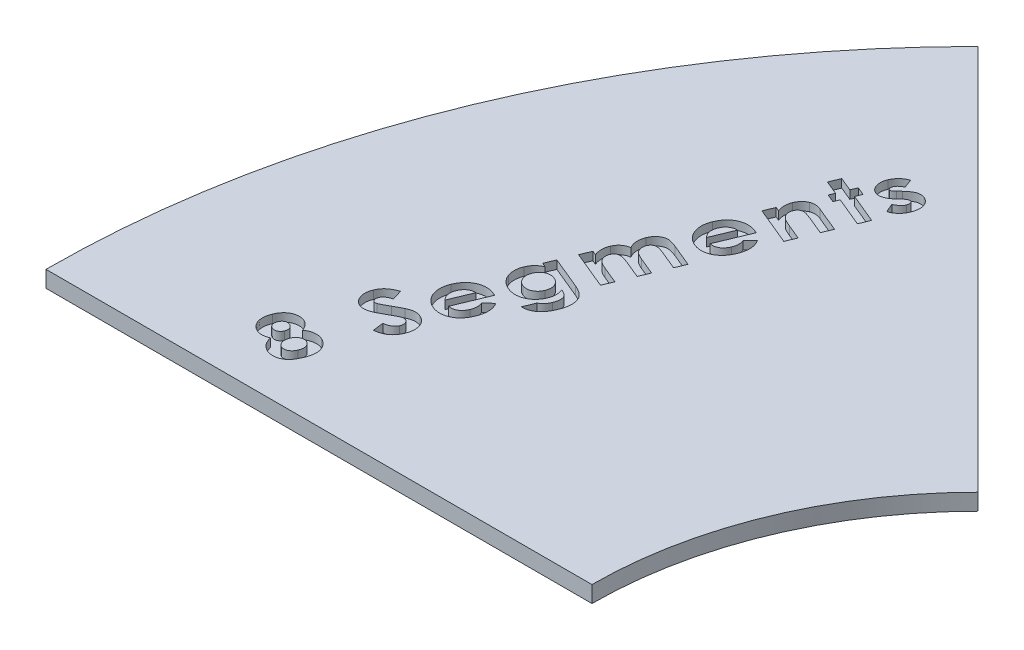
from build123d import *

# Parameters (mm, degrees)
BOSS_EXTRUDE1_DEPTH = 3.175
CUT_EXTRUDE1_DEPTH  = 1.5875


with BuildPart() as part:
    # Sketch1 → Boss-Extrude1 (new body)
    with BuildSketch(Plane(origin=(0, 0, 0), x_dir=(1, 0, 0), z_dir=(0, 1, 0))):
        with BuildLine():
            Line((0, 0), (105.210244843, 0))
            ThreePointArc((105.210244843, 0), (110.873217703, 28.469687102), (127, 52.605122421))
            Line((127, 52.605122421), (52.605122421, 127))
            ThreePointArc((52.605122421, 127), (13.671625882, 68.731904719), (0, 0))
        make_face()
    extrude(amount=BOSS_EXTRUDE1_DEPTH)

    # Sketch2 → Cut-Extrude1 (cut)
    with BuildSketch(Plane(origin=(0, 3.175, 0), x_dir=(1, 0, 0), z_dir=(0, 1, 0))):
        with BuildLine():
            add(Edge.make_bspline(
                [(34.894986461, 14.559342156), (35.015244675, 14.643832063), (35.252004447, 14.810172561), (35.636450357, 15.000750297), (36.033442296, 15.138098122), (36.440193733, 15.223660089), (36.850920666, 15.252640028), (37.258829751, 15.230213215), (37.660350133, 15.150178263), (37.916452634, 15.05473023), (38.04539378, 15.006674554)],
                knots=[0, 0, 0, 0, 1.057196094, 2.081367231, 3.077605999, 4.075701836, 5.06556388, 6.034121002, 7.010229537, 8, 8, 8, 8], degree=3))
            add(Edge.make_bspline(
                [(38.04539378, 15.006674554), (38.114450168, 14.976636756), (38.25139348, 14.917069849), (38.447013485, 14.809469601), (38.633808625, 14.691279857), (38.81046128, 14.559590718), (38.975418947, 14.414146489), (39.134236027, 14.259818954), (39.279788652, 14.088816469), (39.416877323, 13.9079265), (39.54185663, 13.718629218), (39.649321776, 13.521901832), (39.746644523, 13.322884194), (39.824526673, 13.115971452), (39.888127864, 12.904133149), (39.9370112, 12.687343799), (39.970887481, 12.465637209), (39.990662115, 12.238273523), (39.991397687, 12.003820147), (39.980077576, 11.761401268), (39.946237507, 11.511837077), (39.900280263, 11.252401236), (39.833291884, 10.985516856), (39.753496565, 10.708228606), (39.652658128, 10.424667221), (39.57670248, 10.234175591), (39.537915147, 10.136899581)],
                knots=[0, 0, 0, 0, 0.945079064, 1.874153276, 2.799661624, 3.718896423, 4.637060028, 5.559372917, 6.496756723, 7.453262601, 8.408120892, 9.341464594, 10.26616447, 11.187324281, 12.113682889, 13.041442723, 13.975081607, 14.927835092, 15.903895109, 16.916806437, 17.972234812, 19.063457995, 20.22340173, 21.425148361, 22.68513229, 24, 24, 24, 24], degree=3))
            add(Edge.make_bspline(
                [(39.537915147, 10.136899581), (39.494252939, 10.034044784), (39.409210207, 9.833710138), (39.270447786, 9.546949781), (39.129305191, 9.279744341), (38.983089664, 9.033333967), (38.832677483, 8.808026402), (38.678067017, 8.603713616), (38.51831843, 8.420613594), (38.355155034, 8.256421034), (38.184993864, 8.110732368), (38.009388956, 7.978507945), (37.825032054, 7.862872274), (37.634197459, 7.759328609), (37.43626357, 7.671228285), (37.2307295, 7.596544531), (37.018482456, 7.534496283), (36.726700487, 7.47355268), (36.354509755, 7.432201078), (35.905528852, 7.456202082), (35.455490199, 7.539344886), (35.16717524, 7.646353609), (35.020069928, 7.700952065)],
                knots=[0, 0, 0, 0, 1.153938997, 2.247575859, 3.289190737, 4.274343085, 5.205562773, 6.085844791, 6.918733811, 7.713557295, 8.474373638, 9.23055424, 9.981822346, 10.71989077, 11.471371589, 12.217195007, 12.977170591, 13.753067799, 15.294251767, 16.828784307, 18.381968536, 20, 20, 20, 20], degree=3))
            add(Edge.make_bspline(
                [(35.020069928, 7.700952065), (34.89598745, 7.75691979), (34.652186862, 7.86688668), (34.320880074, 8.089003514), (34.02111523, 8.342574627), (33.761212656, 8.639983628), (33.533228131, 8.972446173), (33.350360815, 9.347282833), (33.190312805, 9.754319825), (33.121837813, 10.044639747), (33.086576338, 10.194141168)],
                knots=[0, 0, 0, 0, 0.990997465, 1.947138454, 2.897303808, 3.846462571, 4.818345321, 5.827714344, 6.881372701, 8, 8, 8, 8], degree=3))
            add(Edge.make_bspline(
                [(33.086576338, 10.194141168), (32.982018661, 10.149745312), (32.777390437, 10.062858866), (32.463754098, 9.968720811), (32.155748833, 9.900366576), (31.851408462, 9.869332156), (31.552730989, 9.867706568), (31.260078291, 9.903385299), (30.971689888, 9.966904356), (30.787683151, 10.037697463), (30.695150056, 10.073297818)],
                knots=[0, 0, 0, 0, 1.104929131, 2.162439829, 3.182414216, 4.171487361, 5.134527059, 6.083335384, 7.036149921, 8, 8, 8, 8], degree=3))
            add(Edge.make_bspline(
                [(30.695150056, 10.073297818), (30.572486902, 10.129994294), (30.330989453, 10.241617499), (30.002396806, 10.466557425), (29.712755533, 10.733525045), (29.460742914, 11.039109688), (29.258409236, 11.381910636), (29.101158144, 11.750694676), (29.000408078, 12.146801232), (28.946583584, 12.56407002), (28.950854483, 13.000001062), (29.00588371, 13.447747831), (29.119878444, 13.904746651), (29.233403493, 14.204226222), (29.291671157, 14.357936573)],
                knots=[0, 0, 0, 0, 0.962683188, 1.895316776, 2.826532283, 3.765074047, 4.710051971, 5.65665559, 6.61529115, 7.616384876, 8.649856013, 9.71660434, 10.828028409, 12, 12, 12, 12], degree=3))
            add(Edge.make_bspline(
                [(29.291671157, 14.357936573), (29.35745835, 14.506016706), (29.485665547, 14.794597775), (29.731562937, 15.187686738), (30.001455547, 15.54024706), (30.309886438, 15.83997656), (30.641845092, 16.093011291), (30.997718087, 16.296146666), (31.376167552, 16.442021169), (31.77023225, 16.538404654), (32.171237488, 16.57717776), (32.568853779, 16.566995937), (32.957775898, 16.494244209), (33.204233579, 16.404457214), (33.328263037, 16.359272044)],
                knots=[0, 0, 0, 0, 1.158258468, 2.257233707, 3.309350479, 4.328585269, 5.324889877, 6.289658742, 7.250416187, 8.218215741, 9.183898784, 10.125049342, 11.0564339, 12, 12, 12, 12], degree=3))
            add(Edge.make_bspline(
                [(33.328263037, 16.359272044), (33.413353168, 16.321650946), (33.581221909, 16.24743075), (33.813381767, 16.10327124), (34.025073948, 15.937344084), (34.218056168, 15.743268931), (34.399939361, 15.514908461), (34.573528731, 15.24123664), (34.739118342, 14.917504671), (34.841208602, 14.682915939), (34.894986461, 14.559342156)],
                knots=[0, 0, 0, 0, 0.90715432, 1.789665305, 2.659004758, 3.527166782, 4.454652015, 5.503172596, 6.684751796, 8, 8, 8, 8], degree=3))
        make_face()
        with BuildLine():
            add(Edge.make_bspline(
                [(31.055560046, 13.552314244), (31.026568356, 13.471856019), (30.970425321, 13.316046924), (30.935009289, 13.074113914), (30.950308706, 12.838171831), (31.012119872, 12.613384214), (31.115645532, 12.406252929), (31.260566029, 12.227569058), (31.442583154, 12.078345462), (31.585906455, 12.011541863), (31.659776792, 11.977110585)],
                knots=[0, 0, 0, 0, 1.084156143, 2.099491825, 3.079714819, 4.065958418, 5.04123908, 5.998516089, 6.968414138, 8, 8, 8, 8], degree=3))
            add(Edge.make_bspline(
                [(31.659776792, 11.977110585), (31.737379209, 11.94980408), (31.888214393, 11.896728649), (32.126576488, 11.873078822), (32.361932824, 11.902030753), (32.590595355, 11.979381438), (32.803509969, 12.098062438), (32.987116004, 12.259627139), (33.14177674, 12.455079341), (33.213180267, 12.607166797), (33.249820863, 12.685210211)],
                knots=[0, 0, 0, 0, 1.014990233, 1.972828228, 2.932579668, 3.92791117, 4.941884171, 5.927219846, 6.93635646, 8, 8, 8, 8], degree=3))
            add(Edge.make_bspline(
                [(33.249820863, 12.685210211), (33.279653476, 12.767745356), (33.337427199, 12.9275826), (33.37303614, 13.176276882), (33.354794684, 13.418477953), (33.291553992, 13.650084372), (33.183162911, 13.863452395), (33.03240297, 14.049549734), (32.838114367, 14.201736444), (32.687547163, 14.272516002), (32.609563117, 14.309175222)],
                knots=[0, 0, 0, 0, 1.07396406, 2.079834688, 3.052591258, 4.031998903, 5.004485396, 5.965130557, 6.946069604, 8, 8, 8, 8], degree=3))
            add(Edge.make_bspline(
                [(32.609563117, 14.309175222), (32.532682574, 14.336387459), (32.383976827, 14.389022573), (32.150377259, 14.413943628), (31.92258137, 14.381884461), (31.70335383, 14.303327533), (31.50098752, 14.176755877), (31.322692758, 14.007620144), (31.16891758, 13.798139139), (31.094415997, 13.636576487), (31.055560046, 13.552314244)],
                knots=[0, 0, 0, 0, 1.006594127, 1.946998898, 2.873111781, 3.829953932, 4.807657852, 5.803449211, 6.854399243, 8, 8, 8, 8], degree=3))
        make_face(mode=Mode.SUBTRACT)
        with BuildLine():
            add(Edge.make_bspline(
                [(34.996749282, 12.011031525), (34.952922841, 11.892800801), (34.867977924, 11.663644638), (34.813568255, 11.30702709), (34.818057477, 10.958786678), (34.877383076, 10.678183104), (34.952672786, 10.467395422), (35.021986639, 10.321886211), (35.097944669, 10.187237276), (35.19243766, 10.071053266), (35.290694987, 9.961676331), (35.406907995, 9.872653973), (35.530578398, 9.791371736), (35.620820138, 9.750581167), (35.66668785, 9.729848299)],
                knots=[0, 0, 0, 0, 1.717655024, 3.329178916, 4.892385349, 6.449626005, 7.218668733, 7.943729169, 8.648610728, 9.322160396, 9.984211036, 10.650186634, 11.313922241, 12, 12, 12, 12], degree=3))
            add(Edge.make_bspline(
                [(35.66668785, 9.729848299), (35.763795078, 9.695105946), (35.954720773, 9.626797869), (36.26049234, 9.612390345), (36.566095605, 9.655514044), (36.811995768, 9.754748379), (37.004446062, 9.857935268), (37.139647981, 9.957475182), (37.268339722, 10.067758598), (37.386458677, 10.193737628), (37.498374455, 10.332494571), (37.598950395, 10.487040845), (37.691131156, 10.655781305), (37.743146008, 10.775303839), (37.769786141, 10.836518972)],
                knots=[0, 0, 0, 0, 1.391368532, 2.735615157, 4.101577094, 5.548329535, 6.30311976, 7.058335613, 7.819123302, 8.598569138, 9.396179257, 10.233328724, 11.095174654, 12, 12, 12, 12], degree=3))
            add(Edge.make_bspline(
                [(37.769786141, 10.836518972), (37.794860907, 10.899043064), (37.843833645, 11.021156906), (37.898132701, 11.206661963), (37.939370648, 11.386305616), (37.963298865, 11.561571376), (37.969385502, 11.731956201), (37.960923994, 11.897939184), (37.938560717, 12.059505358), (37.897331226, 12.214762669), (37.843466248, 12.362195507), (37.774249697, 12.498370201), (37.696864495, 12.625497032), (37.601777075, 12.738045142), (37.495358177, 12.840640809), (37.375596051, 12.931801416), (37.244179271, 13.013669732), (37.148483313, 13.055938662), (37.099847572, 13.077421082)],
                knots=[0, 0, 0, 0, 1.230493708, 2.403238625, 3.528140521, 4.596690784, 5.630649897, 6.639375739, 7.63117503, 8.605411454, 9.569839013, 10.493990592, 11.393444885, 12.283109541, 13.178288218, 14.09017477, 15.029365836, 16, 16, 16, 16], degree=3))
            add(Edge.make_bspline(
                [(37.099847572, 13.077421082), (37.04996952, 13.095947768), (36.951556352, 13.13250232), (36.799904893, 13.171973006), (36.647436699, 13.18998884), (36.495121625, 13.193468597), (36.34399195, 13.174608253), (36.191467869, 13.14363987), (36.039633118, 13.092076622), (35.88937236, 13.024138677), (35.744973163, 12.942046835), (35.607176587, 12.848928273), (35.482023041, 12.739339518), (35.365842237, 12.618110114), (35.255827314, 12.486414578), (35.159732119, 12.339692739), (35.07107185, 12.181267553), (35.021943273, 12.068738426), (34.996749282, 12.011031525)],
                knots=[0, 0, 0, 0, 0.970593606, 1.915054551, 2.850672034, 3.766261023, 4.687552417, 5.623258748, 6.6018704, 7.606057281, 8.628050718, 9.629501955, 10.635095203, 11.656437688, 12.691605124, 13.760902874, 14.851751903, 16, 16, 16, 16], degree=3))
        make_face(mode=Mode.SUBTRACT)
        with BuildLine():
            Line((37.82377329, 30.509227798), (38.421629861, 28.526972857))
            add(Edge.make_bspline(
                [(38.421629861, 28.526972857), (38.315779379, 28.496135542), (38.111482739, 28.436618007), (37.825363384, 28.323698511), (37.568333869, 28.19920292), (37.342928027, 28.059438331), (37.147100309, 27.906650133), (36.984096023, 27.737817705), (36.851939662, 27.554206932), (36.788687547, 27.420669003), (36.757383734, 27.354580362)],
                knots=[0, 0, 0, 0, 1.255085698, 2.422377185, 3.498629962, 4.503637447, 5.437583008, 6.319883282, 7.168501178, 8, 8, 8, 8], degree=3))
            add(Edge.make_bspline(
                [(36.757383734, 27.354580362), (36.733463573, 27.290875941), (36.687533248, 27.168553822), (36.653097371, 26.980843259), (36.649729543, 26.800644305), (36.680077496, 26.63152309), (36.733404095, 26.480577195), (36.807596005, 26.353066363), (36.905401513, 26.255680549), (36.98371708, 26.214998123), (37.022391079, 26.19490822)],
                knots=[0, 0, 0, 0, 1.243573393, 2.387848927, 3.47452098, 4.525100094, 5.515332756, 6.391621974, 7.205746542, 8, 8, 8, 8], degree=3))
            add(Edge.make_bspline(
                [(37.022391079, 26.19490822), (37.063685249, 26.180503164), (37.147413656, 26.151295352), (37.281538553, 26.138544217), (37.421596578, 26.145992639), (37.51315055, 26.171177011), (37.560886004, 26.184307926)],
                knots=[0, 0, 0, 0, 0.95245967, 1.931215204, 2.921353408, 4, 4, 4, 4], degree=3))
            add(Edge.make_bspline(
                [(37.560886004, 26.184307926), (37.599199766, 26.198054028), (37.688184769, 26.229979813), (37.836052385, 26.295267844), (38.018846877, 26.379881817), (38.233929046, 26.488404889), (38.482717167, 26.619023401), (38.766565482, 26.768106505), (39.082072744, 26.943286407), (39.303600258, 27.066915343), (39.420177537, 27.131974192)],
                knots=[0, 0, 0, 0, 0.467592245, 1.08599873, 1.856165475, 2.782174495, 3.853593694, 5.08498372, 6.465993399, 8, 8, 8, 8], degree=3))
            add(Edge.make_bspline(
                [(39.420177537, 27.131974192), (39.528117194, 27.1937816), (39.732971562, 27.311083414), (40.026595124, 27.472608842), (40.284699551, 27.62097328), (40.512738269, 27.745239742), (40.709370297, 27.848888352), (40.871371631, 27.936773891), (41.003072849, 28.002838084), (41.08081923, 28.038802463), (41.114104487, 28.054199753)],
                knots=[0, 0, 0, 0, 1.547400198, 2.936749091, 4.169008029, 5.25096652, 6.167378643, 6.934330828, 7.543759182, 8, 8, 8, 8], degree=3))
            add(Edge.make_bspline(
                [(41.114104487, 28.054199753), (41.246196869, 28.111211198), (41.499372148, 28.220482362), (41.874516302, 28.347311925), (42.226146744, 28.42865683), (42.556595124, 28.47256976), (42.874651776, 28.470396218), (43.188125851, 28.438431354), (43.499392547, 28.362740742), (43.700568742, 28.287372275), (43.802338995, 28.249245159)],
                knots=[0, 0, 0, 0, 1.240787128, 2.378158539, 3.410341221, 4.350204943, 5.246327956, 6.147743487, 7.062987476, 8, 8, 8, 8], degree=3))
            add(Edge.make_bspline(
                [(43.802338995, 28.249245159), (43.899410203, 28.205947867), (44.089739593, 28.121054031), (44.354486877, 27.962768747), (44.593754467, 27.781151328), (44.809524353, 27.577192325), (44.998340286, 27.348192906), (45.165510844, 27.099013619), (45.305121085, 26.826106386), (45.418815167, 26.534038736), (45.506243412, 26.227597535), (45.560500017, 25.910541691), (45.586487599, 25.58696123), (45.580366312, 25.25662815), (45.538359865, 24.920549065), (45.467141252, 24.577824671), (45.369199285, 24.226459642), (45.277920254, 23.995665491), (45.2312586, 23.877683995)],
                knots=[0, 0, 0, 0, 0.989442286, 1.940018594, 2.865580513, 3.782865304, 4.699039251, 5.624694804, 6.572714812, 7.548219353, 8.540154878, 9.535818554, 10.53952318, 11.560054073, 12.607635655, 13.689506505, 14.818880466, 16, 16, 16, 16], degree=3))
            add(Edge.make_bspline(
                [(45.2312586, 23.877683995), (45.191302287, 23.786048105), (45.112807963, 23.606029058), (44.978829992, 23.347458048), (44.829510294, 23.106543633), (44.671617798, 22.878318549), (44.498322106, 22.668742724), (44.316655716, 22.471409333), (44.118179463, 22.294344519), (43.909800907, 22.130092258), (43.688576665, 21.979644785), (43.449779605, 21.850163234), (43.198740732, 21.729726213), (42.931646737, 21.625930201), (42.648235412, 21.540436513), (42.350927691, 21.46462351), (42.037443264, 21.408922627), (41.823032738, 21.381479505), (41.714081116, 21.367534422)],
                knots=[0, 0, 0, 0, 1.050302474, 2.063323122, 3.056720699, 4.027035708, 4.976903813, 5.912087026, 6.842689239, 7.76818148, 8.69910954, 9.649732038, 10.619649156, 11.623565597, 12.657064265, 13.728676382, 14.845838428, 16, 16, 16, 16], degree=3))
            Line((41.714081116, 21.367534422), (41.470274359, 23.44095189))
            add(Edge.make_bspline(
                [(41.470274359, 23.44095189), (41.597874584, 23.461481197), (41.843132139, 23.500940121), (42.190290651, 23.591114307), (42.499433058, 23.70856202), (42.774083375, 23.844807856), (43.011070436, 24.008821264), (43.206991253, 24.200169963), (43.372356565, 24.41142543), (43.446947887, 24.571354939), (43.484330181, 24.651505442)],
                knots=[0, 0, 0, 0, 1.259437608, 2.420737008, 3.489065932, 4.47801951, 5.403001476, 6.284802643, 7.140409212, 8, 8, 8, 8], degree=3))
            add(Edge.make_bspline(
                [(43.484330181, 24.651505442), (43.515307793, 24.73550656), (43.575354266, 24.898332892), (43.618567232, 25.150098893), (43.616773819, 25.395648414), (43.572023442, 25.629221663), (43.49413629, 25.84087318), (43.3848602, 26.021119868), (43.242618126, 26.162831541), (43.126523205, 26.221071676), (43.068798664, 26.250029748)],
                knots=[0, 0, 0, 0, 1.177356981, 2.282168659, 3.343301441, 4.39479724, 5.399223176, 6.298042895, 7.153755474, 8, 8, 8, 8], degree=3))
            add(Edge.make_bspline(
                [(43.068798664, 26.250029748), (43.012097023, 26.269244416), (42.896023617, 26.308578585), (42.705488431, 26.325629741), (42.502818617, 26.30879328), (42.323344834, 26.270302486), (42.167561818, 26.2165372), (42.027228129, 26.163710231), (41.870999603, 26.09029422), (41.692805491, 26.005682612), (41.497573473, 25.902834987), (41.279417133, 25.789705504), (41.046095933, 25.654561416), (40.883046842, 25.56095224), (40.798215732, 25.512249299)],
                knots=[0, 0, 0, 0, 0.872511462, 1.786110147, 2.769923426, 3.837503738, 4.458039612, 5.177296719, 6.027769003, 6.979340795, 8.060226658, 9.252196877, 10.570374197, 12, 12, 12, 12], degree=3))
            add(Edge.make_bspline(
                [(40.798215732, 25.512249299), (40.636768492, 25.418291978), (40.327420001, 25.238260684), (39.875916633, 24.989743463), (39.460308845, 24.769283267), (39.078512145, 24.579007119), (38.729759327, 24.422585413), (38.417107964, 24.291135152), (38.136723306, 24.192728941), (37.885943863, 24.122577908), (37.655420813, 24.076945504), (37.436458559, 24.049521617), (37.223977862, 24.03632557), (37.017842415, 24.038563734), (36.818327752, 24.054213549), (36.625877152, 24.089818573), (36.43901836, 24.136275357), (36.320221605, 24.183076443), (36.261289984, 24.206293103)],
                knots=[0, 0, 0, 0, 1.834395707, 3.514879204, 5.060893315, 6.454463483, 7.703134294, 8.814085874, 9.784205908, 10.619323197, 11.369267195, 12.089764372, 12.78501841, 13.458239954, 14.112963858, 14.747362741, 15.378603024, 16, 16, 16, 16], degree=3))
            add(Edge.make_bspline(
                [(36.261289984, 24.206293103), (36.179051838, 24.243297202), (36.017146128, 24.316148736), (35.792546523, 24.457081682), (35.586290328, 24.616781724), (35.402351754, 24.802793411), (35.235720499, 25.008372403), (35.092082829, 25.239351975), (34.966914122, 25.4907599), (34.860893541, 25.76059668), (34.781765989, 26.044170292), (34.728172147, 26.333662834), (34.7026377, 26.625441898), (34.704965961, 26.919994547), (34.734863681, 27.217340507), (34.79288318, 27.51725292), (34.877596486, 27.820276519), (34.954358969, 28.018739196), (34.993494845, 28.119921575)],
                knots=[0, 0, 0, 0, 0.945777067, 1.861991267, 2.776250795, 3.678601881, 4.602086906, 5.548969159, 6.527780765, 7.547332088, 8.587858808, 9.613788023, 10.634121904, 11.658010215, 12.701890797, 13.767017058, 14.861556599, 16, 16, 16, 16], degree=3))
            add(Edge.make_bspline(
                [(34.993494845, 28.119921575), (35.051412187, 28.247898206), (35.166706845, 28.502658203), (35.390158087, 28.857694086), (35.650013234, 29.186384344), (35.899194692, 29.436819916), (36.120787594, 29.625574272), (36.308056497, 29.763315189), (36.514921501, 29.8962594), (36.738700914, 30.028654847), (36.984824552, 30.151941134), (37.245700311, 30.278027397), (37.527916493, 30.396627592), (37.723196766, 30.470949356), (37.82377329, 30.509227798)],
                knots=[0, 0, 0, 0, 1.320847626, 2.629379544, 3.936135346, 5.257719604, 5.946690134, 6.674352171, 7.443653319, 8.260426475, 9.120106871, 10.03345656, 10.987157783, 12, 12, 12, 12], degree=3))
        make_face()
        with BuildLine():
            Line((47.556724494, 38.901769906), (44.957532453, 32.626395974))
            add(Edge.make_bspline(
                [(44.957532453, 32.626395974), (45.025199345, 32.613270861), (45.158406707, 32.58743309), (45.359182313, 32.568258044), (45.555891653, 32.567737479), (45.748800531, 32.587811827), (45.937915502, 32.623097051), (46.12333535, 32.678649479), (46.303786456, 32.753736366), (46.479998682, 32.844722676), (46.649668816, 32.953127501), (46.811285652, 33.077434314), (46.959708189, 33.221571499), (47.099789183, 33.378991973), (47.232602539, 33.550356808), (47.350422738, 33.741371479), (47.461453313, 33.946160077), (47.524585571, 34.091546396), (47.556724494, 34.165558634)],
                knots=[0, 0, 0, 0, 0.999506199, 1.967603067, 2.921040898, 3.848324603, 4.777250371, 5.708154082, 6.650559525, 7.608890338, 8.581536354, 9.567917048, 10.561305486, 11.577859283, 12.623615545, 13.701638693, 14.829966497, 16, 16, 16, 16], degree=3))
            add(Edge.make_bspline(
                [(47.556724494, 34.165558634), (47.591603563, 34.256162844), (47.660439128, 34.434974725), (47.733523657, 34.709264402), (47.78407444, 34.982079049), (47.804620084, 35.254904549), (47.800480911, 35.52742066), (47.770821809, 35.800103394), (47.713951642, 36.072165481), (47.655924241, 36.249344881), (47.626686433, 36.338618864)],
                knots=[0, 0, 0, 0, 1.046210875, 2.064748831, 3.055749339, 4.034100705, 5.009599036, 5.990795142, 6.987637831, 8, 8, 8, 8], degree=3))
            Line((47.626686433, 36.338618864), (49.025925215, 37.689096295))
            add(Edge.make_bspline(
                [(49.025925215, 37.689096295), (49.069803153, 37.609648459), (49.156474624, 37.452716271), (49.2720523, 37.212051422), (49.369516993, 36.968312516), (49.449799795, 36.72157632), (49.516019381, 36.474071418), (49.565253936, 36.224113648), (49.597096853, 35.971920628), (49.611174861, 35.716948566), (49.611984306, 35.458508878), (49.593883884, 35.195976429), (49.562749991, 34.928263342), (49.51309875, 34.655880341), (49.447704782, 34.378344323), (49.363443595, 34.096026894), (49.267376799, 33.807325578), (49.190205416, 33.616078529), (49.151008682, 33.518940712)],
                knots=[0, 0, 0, 0, 1.003634881, 1.982465802, 2.950503462, 3.904525821, 4.850510779, 5.782443743, 6.719866401, 7.659339425, 8.605033763, 9.576189917, 10.567916247, 11.584342194, 12.636469959, 13.719720965, 14.841805265, 16, 16, 16, 16], degree=3))
            add(Edge.make_bspline(
                [(49.151008682, 33.518940712), (49.086431255, 33.370708787), (48.960026669, 33.080557943), (48.731040205, 32.67508994), (48.480590572, 32.303203855), (48.203924924, 31.966487764), (47.90235134, 31.664508377), (47.576280271, 31.397112514), (47.223809898, 31.167425425), (46.851035, 30.973374808), (46.464988697, 30.819757717), (46.074030421, 30.705303046), (45.680932018, 30.635461203), (45.285060203, 30.606720642), (44.887576667, 30.62448545), (44.48800122, 30.685473165), (44.085533046, 30.785311254), (43.824444792, 30.887125349), (43.691857373, 30.938829201)],
                knots=[0, 0, 0, 0, 1.146602934, 2.244373534, 3.298563833, 4.324518666, 5.331476356, 6.322147264, 7.310976432, 8.311232562, 9.299158661, 10.254479451, 11.19676241, 12.126690195, 13.065216707, 14.013338492, 14.991121514, 16, 16, 16, 16], degree=3))
            add(Edge.make_bspline(
                [(43.691857373, 30.938829201), (43.558388156, 30.997664621), (43.295840929, 31.113399745), (42.93085981, 31.329601505), (42.596828876, 31.572000473), (42.296938185, 31.844995401), (42.027401555, 32.145534007), (41.791950458, 32.476093305), (41.586549042, 32.834068198), (41.419375026, 33.218724911), (41.286102691, 33.617920578), (41.193525487, 34.026226745), (41.145509009, 34.439090652), (41.136377539, 34.855897253), (41.170751633, 35.276456198), (41.24942465, 35.700213783), (41.363922709, 36.129830986), (41.473632975, 36.410224177), (41.529397437, 36.552744799)],
                knots=[0, 0, 0, 0, 1.039554709, 2.044907523, 3.018774064, 3.978622492, 4.931724432, 5.8926442, 6.867918403, 7.869968102, 8.878902825, 9.865700747, 10.850372433, 11.838482467, 12.834696674, 13.854002584, 14.909214283, 16, 16, 16, 16], degree=3))
            add(Edge.make_bspline(
                [(41.529397437, 36.552744799), (41.595003999, 36.700806294), (41.723558624, 36.990929559), (41.950800581, 37.400031494), (42.206042824, 37.771739849), (42.484354568, 38.109371433), (42.788902092, 38.410166962), (43.119849384, 38.674341185), (43.475181863, 38.904669147), (43.854024219, 39.096924665), (44.248310114, 39.248954468), (44.652451619, 39.358552339), (45.064058918, 39.423059541), (45.482902277, 39.439050361), (45.908477025, 39.411046037), (46.339880456, 39.337425137), (46.779440766, 39.221908376), (47.066574109, 39.109649086), (47.213274975, 39.052294078)],
                knots=[0, 0, 0, 0, 1.112351366, 2.179628199, 3.209947748, 4.206534332, 5.181656861, 6.145483003, 7.111166465, 8.086192275, 9.059172646, 10.009709944, 10.958099272, 11.915445672, 12.88377453, 13.883196023, 14.918492108, 16, 16, 16, 16], degree=3))
            Line((47.213274975, 39.052294078), (47.556724494, 38.901769906))
        make_face()
        with BuildLine():
            add(Edge.make_bspline(
                [(45.320062501, 37.530091888), (45.207477503, 37.534360857), (44.983363448, 37.542858758), (44.649192885, 37.479110021), (44.324682239, 37.358529938), (44.015869771, 37.179199278), (43.727131161, 36.955071759), (43.477692589, 36.679593542), (43.258853768, 36.367260962), (43.15252669, 36.132161107), (43.09824092, 36.012129815)],
                knots=[0, 0, 0, 0, 0.937368577, 1.865945521, 2.815397792, 3.813532689, 4.833709448, 5.851720568, 6.903186246, 8, 8, 8, 8], degree=3))
            add(Edge.make_bspline(
                [(43.09824092, 36.012129815), (43.048045851, 35.877675673), (42.950010009, 35.615073686), (42.877195738, 35.206272309), (42.861989564, 34.800744535), (42.906436451, 34.53690467), (42.928636219, 34.405125274)],
                knots=[0, 0, 0, 0, 1.048066872, 2.046976308, 3.024528454, 4, 4, 4, 4], degree=3))
            add(Edge.make_bspline(
                [(42.928636219, 34.405125274), (42.952875203, 34.318651467), (43.004124245, 34.135817901), (43.141781456, 33.864882025), (43.330581924, 33.581801988), (43.484944899, 33.398006219), (43.566773906, 33.30057466)],
                knots=[0, 0, 0, 0, 0.835012607, 1.765486412, 2.815467062, 4, 4, 4, 4], degree=3))
            Line((43.566773906, 33.30057466), (45.320062501, 37.530091888))
        make_face(mode=Mode.SUBTRACT)
        with BuildLine():
            Line((46.84390101, 48.856362958), (47.649523339, 50.8025769))
            Line((47.649523339, 50.8025769), (53.82313445, 48.243665976))
            add(Edge.make_bspline(
                [(53.82313445, 48.243665976), (53.969589142, 48.180542422), (54.25309424, 48.058348662), (54.650536967, 47.849987075), (55.007593733, 47.629601918), (55.326580231, 47.398871752), (55.603180779, 47.153203618), (55.838297398, 46.894111458), (56.038221431, 46.625762675), (56.136588021, 46.431153911), (56.18487991, 46.335613091)],
                knots=[0, 0, 0, 0, 1.232213278, 2.385302534, 3.464452739, 4.472752186, 5.424340862, 6.317473201, 7.173983813, 8, 8, 8, 8], degree=3))
            add(Edge.make_bspline(
                [(56.18487991, 46.335613091), (56.240996359, 46.204794717), (56.353486738, 45.942557733), (56.453951851, 45.521616078), (56.509413423, 45.085182154), (56.515749602, 44.629209154), (56.46721996, 44.15537471), (56.366964772, 43.663674689), (56.221363711, 43.15245758), (56.088182732, 42.813167023), (56.019515326, 42.638230613)],
                knots=[0, 0, 0, 0, 0.894840978, 1.793787764, 2.713246973, 3.661089344, 4.658149883, 5.706170744, 6.817313807, 8, 8, 8, 8], degree=3))
            add(Edge.make_bspline(
                [(56.019515326, 42.638230613), (55.94083962, 42.45610552), (55.789671226, 42.106168301), (55.530386424, 41.621154557), (55.257498393, 41.1951123), (54.970107071, 40.825051161), (54.66269993, 40.510765068), (54.341307378, 40.237688165), (53.998384968, 40.010566487), (53.638489571, 39.824404418), (53.262954043, 39.68333757), (52.871700192, 39.592661474), (52.468243787, 39.543449719), (52.195044443, 39.550158386), (52.057125503, 39.553545116)],
                knots=[0, 0, 0, 0, 1.323873625, 2.543705805, 3.666386811, 4.697831038, 5.665251407, 6.596001571, 7.507912599, 8.404566619, 9.295681651, 10.177861967, 11.080131959, 12, 12, 12, 12], degree=3))
            Line((52.057125503, 39.553545116), (52.949670241, 41.707524817))
            add(Edge.make_bspline(
                [(52.949670241, 41.707524817), (53.019922039, 41.737379978), (53.161024173, 41.797344665), (53.35743037, 41.924454222), (53.544779895, 42.075279045), (53.722098147, 42.255092044), (53.886371199, 42.465028969), (54.04488273, 42.699947002), (54.185536262, 42.967436413), (54.269482559, 43.157129674), (54.312868024, 43.255167712)],
                knots=[0, 0, 0, 0, 0.862758365, 1.732867346, 2.637491876, 3.582264396, 4.584342987, 5.651654991, 6.786318835, 8, 8, 8, 8], degree=3))
            add(Edge.make_bspline(
                [(54.312868024, 43.255167712), (54.361655804, 43.380906652), (54.454740662, 43.620810811), (54.554204208, 43.975259164), (54.606972143, 44.304117757), (54.616072036, 44.606283212), (54.589228041, 44.880638782), (54.531110532, 45.127709619), (54.439121272, 45.345971801), (54.334018374, 45.507029126), (54.228704055, 45.623978929), (54.130255228, 45.709958503), (54.014203396, 45.797972286), (53.879089003, 45.885581358), (53.725746832, 45.975060939), (53.553614172, 46.063786369), (53.362192538, 46.152514746), (53.227554248, 46.210179323), (53.157435999, 46.240210447)],
                knots=[0, 0, 0, 0, 1.727353437, 3.295711531, 4.706883854, 5.984034755, 7.157937912, 8.229585478, 9.223483754, 10.177742941, 10.677775558, 11.235691424, 11.849574508, 12.54267662, 13.297383517, 14.123498569, 15.022737179, 16, 16, 16, 16], degree=3))
            add(Edge.make_bspline(
                [(53.157435999, 46.240210447), (53.19814896, 46.123637887), (53.277794371, 45.895590867), (53.351768205, 45.54808884), (53.397413717, 45.209153046), (53.400313212, 44.874904297), (53.370287887, 44.541124555), (53.304504537, 44.203259309), (53.210647433, 43.855368077), (53.120831048, 43.626822533), (53.074753708, 43.509574763)],
                knots=[0, 0, 0, 0, 1.056011142, 2.065839458, 3.035286268, 3.979082649, 4.920569059, 5.899407769, 6.92236029, 8, 8, 8, 8], degree=3))
            add(Edge.make_bspline(
                [(53.074753708, 43.509574763), (53.018304322, 43.382702256), (52.907131732, 43.132836912), (52.704618866, 42.781683961), (52.474984483, 42.460263434), (52.218855433, 42.167414483), (51.936193608, 41.903798551), (51.626228736, 41.66913509), (51.290438501, 41.463050245), (50.931501441, 41.288861998), (50.559095032, 41.14592571), (50.177815649, 41.046678283), (49.793650211, 40.985605973), (49.40615878, 40.969571389), (49.015416658, 40.992960508), (48.621637657, 41.058119947), (48.223068005, 41.160427073), (47.963780952, 41.261675722), (47.831848393, 41.313193887)],
                knots=[0, 0, 0, 0, 1.04887533, 2.065676805, 3.057127916, 4.029759462, 5.000864989, 5.972851204, 6.962978153, 7.973293486, 8.984018067, 9.972371898, 10.945223346, 11.918133426, 12.897209456, 13.898108625, 14.93049844, 16, 16, 16, 16], degree=3))
            add(Edge.make_bspline(
                [(47.831848393, 41.313193887), (47.693436285, 41.374140266), (47.422483602, 41.493447637), (47.045879226, 41.714012869), (46.704803536, 41.959432803), (46.401159894, 42.234305493), (46.129705006, 42.532727716), (45.898064958, 42.862510862), (45.700347223, 43.217530871), (45.600853357, 43.470839492), (45.550665166, 43.598617231)],
                knots=[0, 0, 0, 0, 1.089297454, 2.132386192, 3.138996283, 4.112750176, 5.07931049, 6.040312062, 7.011464774, 8, 8, 8, 8], degree=3))
            add(Edge.make_bspline(
                [(45.550665166, 43.598617231), (45.511759948, 43.71742995), (45.435050813, 43.951692126), (45.358359788, 44.310938982), (45.318315488, 44.670271393), (45.311753865, 45.030155162), (45.339611261, 45.390043441), (45.401705333, 45.750601152), (45.498452275, 46.111464289), (45.589463519, 46.346255407), (45.635467516, 46.464936676)],
                knots=[0, 0, 0, 0, 1.021469762, 2.014024518, 2.996474523, 3.972927691, 4.952111247, 5.942680252, 6.9600743, 8, 8, 8, 8], degree=3))
            add(Edge.make_bspline(
                [(45.635467516, 46.464936676), (45.683463907, 46.574846614), (45.778257529, 46.791920459), (45.957534634, 47.096615229), (46.158145119, 47.381001964), (46.385980797, 47.645931534), (46.646147132, 47.892004592), (46.94067282, 48.122975175), (47.274789421, 48.335915662), (47.51493976, 48.461036964), (47.638923045, 48.525633791)],
                knots=[0, 0, 0, 0, 0.977264599, 1.930112864, 2.876719183, 3.812457182, 4.774462991, 5.792425057, 6.860287293, 8, 8, 8, 8], degree=3))
            Line((47.638923045, 48.525633791), (46.84390101, 48.856362958))
        make_face()
        with BuildLine():
            add(Edge.make_bspline(
                [(47.507479402, 46.208409566), (47.477711366, 46.132599018), (47.419289091, 45.983814442), (47.358633007, 45.755415464), (47.317960961, 45.530671589), (47.297625072, 45.307776176), (47.302793089, 45.087616787), (47.327191542, 44.869973143), (47.377784503, 44.655926391), (47.446607336, 44.446396407), (47.534665039, 44.244556651), (47.644689439, 44.058008381), (47.766306318, 43.882791908), (47.908149509, 43.725135839), (48.065920408, 43.581401741), (48.242710479, 43.455433061), (48.434304174, 43.341079315), (48.57175401, 43.279930167), (48.641710839, 43.248807536)],
                knots=[0, 0, 0, 0, 1.101528434, 2.161842193, 3.191828104, 4.190245021, 5.185128195, 6.167426775, 7.148840254, 8.156014582, 9.149471532, 10.122271848, 11.082912569, 12.031286026, 12.986052383, 13.965599877, 14.964566382, 16, 16, 16, 16], degree=3))
            add(Edge.make_bspline(
                [(48.641710839, 43.248807536), (48.71621022, 43.220793591), (48.861965699, 43.165985271), (49.084282705, 43.104679986), (49.305653719, 43.072251261), (49.524323388, 43.057516088), (49.741258761, 43.071307714), (49.954883313, 43.107673979), (50.167771315, 43.165071472), (50.37576317, 43.247574874), (50.575036055, 43.351342634), (50.764244053, 43.469553745), (50.93607303, 43.610056804), (51.09804606, 43.763211421), (51.243119982, 43.937739456), (51.373770082, 44.128222085), (51.49225569, 44.335767561), (51.55739241, 44.48345535), (51.590712575, 44.55900385)],
                knots=[0, 0, 0, 0, 1.056649536, 2.067298498, 3.054678616, 4.022832011, 4.972250514, 5.933329505, 6.896239125, 7.894704284, 8.897744739, 9.876526318, 10.851070533, 11.839920996, 12.832326888, 13.857851852, 14.904201353, 16, 16, 16, 16], degree=3))
            add(Edge.make_bspline(
                [(51.590712575, 44.55900385), (51.619235417, 44.634262339), (51.675107922, 44.781683849), (51.741099888, 45.004905673), (51.777271157, 45.227116898), (51.798801984, 45.445480634), (51.792410239, 45.661273749), (51.771655059, 45.875021192), (51.719957127, 46.085027944), (51.653911783, 46.292380339), (51.565376605, 46.49098904), (51.455834446, 46.676176036), (51.331103548, 46.849484822), (51.184987722, 47.007066464), (51.021450168, 47.151977092), (50.837803268, 47.281537126), (50.635595526, 47.396196637), (50.491683615, 47.460423534), (50.418320081, 47.493165175)],
                knots=[0, 0, 0, 0, 1.088538338, 2.132303831, 3.141129993, 4.12937037, 5.094932548, 6.056512618, 7.027970334, 8.013340738, 8.997412282, 9.961317248, 10.919137135, 11.879719099, 12.861606551, 13.869390748, 14.913856227, 16, 16, 16, 16], degree=3))
            add(Edge.make_bspline(
                [(50.418320081, 47.493165175), (50.343897491, 47.522143749), (50.198507404, 47.578755558), (49.976131118, 47.638238259), (49.757458885, 47.67474698), (49.540644291, 47.688090737), (49.326902959, 47.676609625), (49.114551144, 47.646023929), (48.907012935, 47.587004384), (48.703316718, 47.509603773), (48.509094287, 47.408846418), (48.323576011, 47.293444685), (48.153643954, 47.156684673), (47.997488485, 47.001882462), (47.85327536, 46.830720998), (47.723493257, 46.639954699), (47.606471716, 46.432060286), (47.540896421, 46.283907753), (47.507479402, 46.208409566)],
                knots=[0, 0, 0, 0, 1.071828598, 2.093897225, 3.084556853, 4.044703158, 5.004333469, 5.954533221, 6.919171025, 7.89550071, 8.875880427, 9.852625091, 10.82484156, 11.797845044, 12.801464466, 13.825381718, 14.891819553, 16, 16, 16, 16], degree=3))
        make_face(mode=Mode.SUBTRACT)
        with BuildLine():
            Line((48.873320996, 53.757551872), (49.685303502, 55.718606225))
            Line((49.685303502, 55.718606225), (50.514246477, 55.375156706))
            add(Edge.make_bspline(
                [(50.514246477, 55.375156706), (50.467036396, 55.49296955), (50.374131208, 55.724814615), (50.282575445, 56.08473971), (50.223857218, 56.442995525), (50.204740068, 56.802663937), (50.223868051, 57.16302126), (50.282700489, 57.524082137), (50.374477494, 57.887108446), (50.465786651, 58.122177602), (50.512126418, 58.241476151)],
                knots=[0, 0, 0, 0, 1.032359758, 2.031591016, 3.016304825, 3.984319457, 4.95807964, 5.948475553, 6.958843036, 8, 8, 8, 8], degree=3))
            add(Edge.make_bspline(
                [(50.512126418, 58.241476151), (50.565807987, 58.358868055), (50.670980521, 58.588861406), (50.875554754, 58.904214568), (51.114041927, 59.18321413), (51.385095149, 59.427102396), (51.686510756, 59.631176711), (52.015974977, 59.791651815), (52.372591634, 59.905883447), (52.621581512, 59.945065918), (52.748788411, 59.965083923)],
                knots=[0, 0, 0, 0, 1.043084363, 2.043603173, 3.02883443, 4.004399789, 4.984226556, 5.963402779, 6.959519078, 8, 8, 8, 8], degree=3))
            add(Edge.make_bspline(
                [(52.748788411, 59.965083923), (52.679864248, 60.086476406), (52.543469947, 60.326700478), (52.396653186, 60.711204812), (52.295026507, 61.104434599), (52.244571153, 61.5069076), (52.242322931, 61.914083643), (52.28989584, 62.321708661), (52.384809058, 62.727597103), (52.484270042, 62.989272296), (52.534662476, 63.121851418)],
                knots=[0, 0, 0, 0, 1.017703106, 2.013936752, 2.993538965, 3.976286934, 4.966694406, 5.958444259, 6.965634979, 8, 8, 8, 8], degree=3))
            add(Edge.make_bspline(
                [(52.534662476, 63.121851418), (52.594183108, 63.254359267), (52.710562797, 63.513449628), (52.938312036, 63.86411327), (53.196331502, 64.174469207), (53.487889647, 64.436194488), (53.80142592, 64.647210365), (54.125448425, 64.8118849), (54.462684705, 64.909998558), (54.751647272, 64.952835658), (54.994291814, 64.951592881), (55.19641499, 64.934492983), (55.416994168, 64.896678687), (55.656546045, 64.844361221), (55.913948057, 64.769948668), (56.191099528, 64.682165953), (56.486525896, 64.572263332), (56.688749382, 64.491162539), (56.793860526, 64.449008202)],
                knots=[0, 0, 0, 0, 1.355894932, 2.651158475, 3.893406619, 5.118737246, 6.298434108, 7.417892898, 8.500285189, 9.566967153, 10.1349645, 10.764624214, 11.460620845, 12.224989735, 13.055098816, 13.963684313, 14.941569669, 16, 16, 16, 16], degree=3))
            Line((56.793860526, 64.449008202), (61.021257695, 62.697839666))
            Line((61.021257695, 62.697839666), (60.207155131, 60.730425136))
            Line((60.207155131, 60.730425136), (56.550053769, 62.24626715))
            add(Edge.make_bspline(
                [(56.550053769, 62.24626715), (56.451463347, 62.286052093), (56.262703693, 62.362223714), (55.98637194, 62.457058491), (55.731665046, 62.535139651), (55.496600406, 62.590901479), (55.28111358, 62.625346146), (55.086112873, 62.641693095), (54.910710031, 62.636968749), (54.754757033, 62.608579218), (54.613762313, 62.563221612), (54.484251852, 62.501497809), (54.363691266, 62.424088219), (54.25269667, 62.33047174), (54.153207045, 62.218655586), (54.062032471, 62.092766954), (53.97780754, 61.952348187), (53.933436344, 61.849692787), (53.910580612, 61.796814692)],
                knots=[0, 0, 0, 0, 1.661188222, 3.180484568, 4.564111619, 5.823170697, 6.952519519, 7.971500002, 8.877710015, 9.685731988, 10.440123714, 11.186060783, 11.921292823, 12.673579793, 13.447681333, 14.253965541, 15.100612581, 16, 16, 16, 16], degree=3))
            add(Edge.make_bspline(
                [(53.910580612, 61.796814692), (53.879801292, 61.714184853), (53.819126743, 61.551298595), (53.772520807, 61.296329123), (53.767045107, 61.041248471), (53.796211649, 60.788289527), (53.863320241, 60.541554304), (53.972006736, 60.309555333), (54.11075545, 60.089537912), (54.258492264, 59.920891668), (54.400547651, 59.792762052), (54.52913413, 59.69569267), (54.676127814, 59.595671685), (54.843527034, 59.49391085), (55.03275349, 59.393364519), (55.241096531, 59.289039566), (55.469259602, 59.183205061), (55.629720723, 59.115831276), (55.712630558, 59.08101942)],
                knots=[0, 0, 0, 0, 1.139828185, 2.24691649, 3.335903, 4.432051578, 5.532885632, 6.62995002, 7.7364334, 8.890490379, 9.518795375, 10.21044108, 10.9741959, 11.819851654, 12.744910229, 13.747258526, 14.836014457, 16, 16, 16, 16], degree=3))
            Line((55.712630558, 59.08101942), (58.964800697, 57.732662048))
            Line((58.964800697, 57.732662048), (58.150698133, 55.765247518))
            Line((58.150698133, 55.765247518), (54.658961354, 57.211127593))
            add(Edge.make_bspline(
                [(54.658961354, 57.211127593), (54.580610127, 57.242452211), (54.429988222, 57.302670458), (54.210458893, 57.386155477), (54.005736839, 57.458419211), (53.814931449, 57.518368913), (53.638540548, 57.56461646), (53.477646384, 57.601974382), (53.330924838, 57.625142571), (53.158442717, 57.642629488), (52.960355146, 57.640433484), (52.737960775, 57.609816831), (52.534377978, 57.546729229), (52.352140919, 57.449661314), (52.190454487, 57.324534318), (52.049566151, 57.17151251), (51.927153172, 56.992499059), (51.8662698, 56.85814519), (51.835043085, 56.7892359)],
                knots=[0, 0, 0, 0, 1.244160804, 2.391766885, 3.462785924, 4.444910809, 5.339625477, 6.151105519, 6.879155723, 7.528205946, 8.70569774, 9.790265913, 10.828338442, 11.830489771, 12.818401475, 13.828484456, 14.886242748, 16, 16, 16, 16], degree=3))
            add(Edge.make_bspline(
                [(51.835043085, 56.7892359), (51.805890376, 56.707948907), (51.748583264, 56.548158518), (51.70271574, 56.297169069), (51.700305701, 56.04414993), (51.730782251, 55.790089419), (51.803537264, 55.542890537), (51.912677791, 55.306970868), (52.059617079, 55.085871999), (52.211764255, 54.914570575), (52.356999364, 54.782412795), (52.489735867, 54.683951762), (52.640506541, 54.582270942), (52.810359087, 54.477862712), (53.001197421, 54.374840604), (53.211802615, 54.271470742), (53.441260619, 54.16478171), (53.602255755, 54.096286975), (53.685854383, 54.060720275)],
                knots=[0, 0, 0, 0, 1.107821748, 2.177707197, 3.257859614, 4.346405599, 5.452180819, 6.552579829, 7.672712523, 8.849223574, 9.485359809, 10.191453107, 10.969261549, 11.820679422, 12.75069898, 13.753217173, 14.833331462, 16, 16, 16, 16], degree=3))
            Line((53.685854383, 54.060720275), (56.893503288, 52.731443432))
            Line((56.893503288, 52.731443432), (56.081520782, 50.770389078))
            Line((56.081520782, 50.770389078), (48.873320996, 53.757551872))
        make_face()
        with BuildLine():
            Line((62.318697012, 74.540324167), (59.719504972, 68.264950236))
            add(Edge.make_bspline(
                [(59.719504972, 68.264950236), (59.787171863, 68.251825123), (59.920379225, 68.225987352), (60.121154831, 68.206812306), (60.317864171, 68.206291741), (60.510773049, 68.226366089), (60.69988802, 68.261651312), (60.885307868, 68.31720374), (61.065758974, 68.392290628), (61.241971201, 68.483276938), (61.411641335, 68.591681763), (61.57325817, 68.715988575), (61.721680708, 68.86012576), (61.861761702, 69.017546235), (61.994575058, 69.18891107), (62.112395257, 69.379925741), (62.223425831, 69.584714338), (62.286558089, 69.730100658), (62.318697012, 69.804112896)],
                knots=[0, 0, 0, 0, 0.999506199, 1.967603067, 2.921040898, 3.848324603, 4.777250371, 5.708154082, 6.650559525, 7.608890338, 8.581536354, 9.567917048, 10.561305486, 11.577859283, 12.623615545, 13.701638693, 14.829966497, 16, 16, 16, 16], degree=3))
            add(Edge.make_bspline(
                [(62.318697012, 69.804112896), (62.353576081, 69.894717105), (62.422411647, 70.073528987), (62.495496175, 70.347818663), (62.546046958, 70.620633311), (62.566592603, 70.89345881), (62.56245343, 71.165974922), (62.532794327, 71.438657656), (62.47592416, 71.710719743), (62.417896759, 71.887899142), (62.388658951, 71.977173126)],
                knots=[0, 0, 0, 0, 1.046210875, 2.064748831, 3.055749339, 4.034100705, 5.009599036, 5.990795142, 6.987637831, 8, 8, 8, 8], degree=3))
            Line((62.388658951, 71.977173126), (63.787897733, 73.327650556))
            add(Edge.make_bspline(
                [(63.787897733, 73.327650556), (63.831775671, 73.24820272), (63.918447143, 73.091270532), (64.034024818, 72.850605683), (64.131489512, 72.606866778), (64.211772314, 72.360130582), (64.277991899, 72.112625679), (64.327226454, 71.86266791), (64.359069372, 71.61047489), (64.37314738, 71.355502828), (64.373956825, 71.097063139), (64.355856402, 70.83453069), (64.324722509, 70.566817604), (64.275071268, 70.294434603), (64.2096773, 70.016898584), (64.125416113, 69.734581155), (64.029349318, 69.44587984), (63.952177934, 69.25463279), (63.9129812, 69.157494974)],
                knots=[0, 0, 0, 0, 1.003634881, 1.982465802, 2.950503462, 3.904525821, 4.850510779, 5.782443743, 6.719866401, 7.659339425, 8.605033763, 9.576189917, 10.567916247, 11.584342194, 12.636469959, 13.719720965, 14.841805265, 16, 16, 16, 16], degree=3))
            add(Edge.make_bspline(
                [(63.9129812, 69.157494974), (63.848403773, 69.009263049), (63.721999188, 68.719112204), (63.493012723, 68.313644202), (63.242563091, 67.941758117), (62.965897442, 67.605042026), (62.664323858, 67.303062638), (62.33825279, 67.035666776), (61.985782416, 66.805979686), (61.613007519, 66.61192907), (61.226961215, 66.458311978), (60.83600294, 66.343857307), (60.442904536, 66.274015464), (60.047032722, 66.245274903), (59.649549185, 66.263039711), (59.249973739, 66.324027426), (58.847505564, 66.423865515), (58.586417311, 66.525679611), (58.453829892, 66.577383462)],
                knots=[0, 0, 0, 0, 1.146602934, 2.244373534, 3.298563833, 4.324518666, 5.331476356, 6.322147264, 7.310976432, 8.311232562, 9.299158661, 10.254479451, 11.19676241, 12.126690195, 13.065216707, 14.013338492, 14.991121514, 16, 16, 16, 16], degree=3))
            add(Edge.make_bspline(
                [(58.453829892, 66.577383462), (58.320360675, 66.636218882), (58.057813448, 66.751954007), (57.692832329, 66.968155767), (57.358801394, 67.210554734), (57.058910704, 67.483549662), (56.789374074, 67.784088268), (56.553922977, 68.114647566), (56.348521561, 68.47262246), (56.181347545, 68.857279172), (56.048075209, 69.25647484), (55.955498005, 69.664781007), (55.907481528, 70.077644914), (55.898350057, 70.494451514), (55.932724151, 70.91501046), (56.011397169, 71.338768044), (56.125895227, 71.768385248), (56.235605494, 72.048778438), (56.291369956, 72.19129906)],
                knots=[0, 0, 0, 0, 1.039554709, 2.044907523, 3.018774064, 3.978622492, 4.931724432, 5.8926442, 6.867918403, 7.869968102, 8.878902825, 9.865700747, 10.850372433, 11.838482467, 12.834696674, 13.854002584, 14.909214283, 16, 16, 16, 16], degree=3))
            add(Edge.make_bspline(
                [(56.291369956, 72.19129906), (56.356976518, 72.339360556), (56.485531143, 72.629483821), (56.7127731, 73.038585755), (56.968015342, 73.41029411), (57.246327086, 73.747925695), (57.55087461, 74.048721224), (57.881821903, 74.312895447), (58.237154382, 74.543223409), (58.615996737, 74.735478927), (59.010282632, 74.88750873), (59.414424137, 74.997106601), (59.826031437, 75.061613803), (60.244874796, 75.077604622), (60.670449544, 75.049600299), (61.101852974, 74.975979398), (61.541413285, 74.860462638), (61.828546627, 74.748203347), (61.975247493, 74.690848339)],
                knots=[0, 0, 0, 0, 1.112351366, 2.179628199, 3.209947748, 4.206534332, 5.181656861, 6.145483003, 7.111166465, 8.086192275, 9.059172646, 10.009709944, 10.958099272, 11.915445672, 12.88377453, 13.883196023, 14.918492108, 16, 16, 16, 16], degree=3))
            Line((61.975247493, 74.690848339), (62.318697012, 74.540324167))
        make_face()
        with BuildLine():
            add(Edge.make_bspline(
                [(60.08203502, 73.168646149), (59.969450022, 73.172915119), (59.745335967, 73.181413019), (59.411165404, 73.117664283), (59.086654757, 72.997084199), (58.777842289, 72.817753539), (58.489103679, 72.593626021), (58.239665107, 72.318147803), (58.020826287, 72.005815223), (57.914499208, 71.770715368), (57.860213439, 71.650684077)],
                knots=[0, 0, 0, 0, 0.937368577, 1.865945521, 2.815397792, 3.813532689, 4.833709448, 5.851720568, 6.903186246, 8, 8, 8, 8], degree=3))
            add(Edge.make_bspline(
                [(57.860213439, 71.650684077), (57.810018369, 71.516229935), (57.711982527, 71.253627947), (57.639168256, 70.844826571), (57.623962082, 70.439298796), (57.668408969, 70.175458931), (57.690608738, 70.043679536)],
                knots=[0, 0, 0, 0, 1.048066872, 2.046976308, 3.024528454, 4, 4, 4, 4], degree=3))
            add(Edge.make_bspline(
                [(57.690608738, 70.043679536), (57.714847722, 69.957205728), (57.766096764, 69.774372163), (57.903753975, 69.503436287), (58.092554443, 69.220356249), (58.246917418, 69.03656048), (58.328746425, 68.939128922)],
                knots=[0, 0, 0, 0, 0.835012607, 1.765486412, 2.815467062, 4, 4, 4, 4], degree=3))
            Line((58.328746425, 68.939128922), (60.08203502, 73.168646149))
        make_face(mode=Mode.SUBTRACT)
        with BuildLine():
            Line((59.222927482, 78.743197802), (60.028549811, 80.689411744))
            Line((60.028549811, 80.689411744), (60.764210201, 80.384123282))
            add(Edge.make_bspline(
                [(60.764210201, 80.384123282), (60.727898175, 80.525067462), (60.658415997, 80.794760726), (60.585445353, 81.186964858), (60.545785919, 81.547748628), (60.53828097, 81.880589992), (60.562284654, 82.194261807), (60.613463439, 82.496489033), (60.691031628, 82.792021447), (60.763863479, 82.98178808), (60.8002512, 83.076597908)],
                knots=[0, 0, 0, 0, 1.271191684, 2.432394406, 3.481596574, 4.438649646, 5.336361805, 6.225414227, 7.113394339, 8, 8, 8, 8], degree=3))
            add(Edge.make_bspline(
                [(60.8002512, 83.076597908), (60.841648737, 83.170719945), (60.923089377, 83.355884553), (61.07292102, 83.615347166), (61.241180662, 83.854445558), (61.428026578, 84.072857445), (61.632512729, 84.272632912), (61.858360032, 84.447609288), (62.101743528, 84.605293497), (62.276267987, 84.690986892), (62.364854565, 84.734483859)],
                knots=[0, 0, 0, 0, 1.055821384, 2.077098642, 3.072257032, 4.055906002, 5.02638942, 6.003909341, 6.986807679, 8, 8, 8, 8], degree=3))
            add(Edge.make_bspline(
                [(62.364854565, 84.734483859), (62.442654676, 84.76599182), (62.598202407, 84.828986484), (62.844568828, 84.890988537), (63.101833206, 84.919445721), (63.368183867, 84.921053554), (63.645533776, 84.895962521), (63.931453356, 84.836020383), (64.229295768, 84.752669036), (64.426179683, 84.674826862), (64.527314501, 84.634841097)],
                knots=[0, 0, 0, 0, 0.903608208, 1.806606749, 2.726460257, 3.685829882, 4.672251121, 5.720470489, 6.82905721, 8, 8, 8, 8], degree=3))
            Line((64.527314501, 84.634841097), (69.291086536, 82.661066391))
            Line((69.291086536, 82.661066391), (68.489704325, 80.727572802))
            Line((68.489704325, 80.727572802), (65.328696712, 82.037769116))
            add(Edge.make_bspline(
                [(65.328696712, 82.037769116), (65.225535945, 82.079494248), (65.027973228, 82.159401858), (64.744365021, 82.273529987), (64.484186601, 82.367596008), (64.250592837, 82.449286781), (64.042723933, 82.514875288), (63.860209692, 82.567902378), (63.701808384, 82.600636201), (63.529328387, 82.630665779), (63.335839406, 82.636936094), (63.118850598, 82.612516449), (62.916715862, 82.553037058), (62.731944009, 82.457898276), (62.565908838, 82.33196129), (62.419244664, 82.175811318), (62.29280304, 81.989894508), (62.229869963, 81.849503121), (62.197369923, 81.777001888)],
                knots=[0, 0, 0, 0, 1.48280352, 2.839710277, 4.073004623, 5.168870767, 6.136744688, 6.977496249, 7.699616671, 8.290977413, 9.308643867, 10.266387525, 11.189961259, 12.09960514, 13.020534937, 13.953089531, 14.942929933, 16, 16, 16, 16], degree=3))
            add(Edge.make_bspline(
                [(62.197369923, 81.777001888), (62.162063058, 81.679038), (62.093277083, 81.488181589), (62.050496762, 81.188898803), (62.063298433, 80.892019745), (62.132221649, 80.599610733), (62.254519142, 80.319319146), (62.425176145, 80.054284137), (62.646222059, 79.807999125), (62.822697801, 79.666505047), (62.913949784, 79.593341365)],
                knots=[0, 0, 0, 0, 1.001250994, 1.950669535, 2.89115933, 3.849060524, 4.828024374, 5.823354532, 6.874501326, 8, 8, 8, 8], degree=3))
            add(Edge.make_bspline(
                [(62.913949784, 79.593341365), (62.94345906, 79.573287494), (63.009161643, 79.52863743), (63.12307215, 79.460738268), (63.26175123, 79.384478639), (63.429150716, 79.305758194), (63.619111072, 79.212682693), (63.837523755, 79.117576528), (64.079493778, 79.009661397), (64.250802988, 78.939198785), (64.34074933, 78.902202209)],
                knots=[0, 0, 0, 0, 0.539161582, 1.200446529, 2.003455327, 2.930197726, 3.995588527, 5.200480532, 6.530105099, 8, 8, 8, 8], degree=3))
            Line((64.34074933, 78.902202209), (67.236749597, 77.70224895))
            Line((67.236749597, 77.70224895), (66.431127268, 75.756035008))
            Line((66.431127268, 75.756035008), (59.222927482, 78.743197802))
        make_face()
        Polygon((60.719275276, 89.869095418), (61.524897605, 91.81530936), (64.181331232, 90.714998864), (64.662584571, 91.874671006), (66.218707701, 91.230173142), (65.737454363, 90.070501), (71.389531019, 87.72783607), (70.583908689, 85.781622128), (64.931832033, 88.124287058), (64.516300516, 87.123619323), (62.960177386, 87.768117186), (63.375708903, 88.768784921), align=None)
        with BuildLine():
            Line((68.444986155, 98.159163336), (69.064043313, 96.484316915))
            add(Edge.make_bspline(
                [(69.064043313, 96.484316915), (68.985867211, 96.446307539), (68.834523667, 96.372724006), (68.622479909, 96.252159541), (68.433066162, 96.127186596), (68.265844697, 95.998147589), (68.123955277, 95.862275117), (68.003118686, 95.723116291), (67.903614586, 95.579488907), (67.855682198, 95.476614593), (67.832289173, 95.426407594)],
                knots=[0, 0, 0, 0, 1.257020752, 2.433505513, 3.524908842, 4.536997493, 5.484030042, 6.360956482, 7.200077703, 8, 8, 8, 8], degree=3))
            add(Edge.make_bspline(
                [(67.832289173, 95.426407594), (67.812886357, 95.373770274), (67.776170152, 95.274163979), (67.739381881, 95.125765778), (67.731632589, 94.987429188), (67.742207523, 94.860559913), (67.778268091, 94.75009099), (67.832170516, 94.657823001), (67.903895388, 94.584162277), (67.963397558, 94.553546973), (67.993413639, 94.538102973)],
                knots=[0, 0, 0, 0, 1.344266143, 2.543772548, 3.646618002, 4.650925499, 5.577400872, 6.40513068, 7.195462484, 8, 8, 8, 8], degree=3))
            add(Edge.make_bspline(
                [(67.993413639, 94.538102973), (68.017906751, 94.530038109), (68.067378035, 94.513748663), (68.147124501, 94.507549224), (68.229366536, 94.519831279), (68.320464518, 94.545948109), (68.425262638, 94.605812743), (68.554440965, 94.698725355), (68.711575315, 94.830817507), (68.824182851, 94.933399751), (68.885958377, 94.989675489)],
                knots=[0, 0, 0, 0, 0.585870734, 1.183343996, 1.800229781, 2.472381178, 3.32920945, 4.530426431, 6.096621757, 8, 8, 8, 8], degree=3))
            Line((68.885958377, 94.989675489), (69.51349577, 95.57057159))
            add(Edge.make_bspline(
                [(69.51349577, 95.57057159), (69.593490663, 95.643997271), (69.748150038, 95.785955957), (69.981488482, 95.981319229), (70.207692646, 96.153840908), (70.423244056, 96.305914549), (70.631267821, 96.434947303), (70.829741873, 96.541712701), (71.021418333, 96.624877868), (71.262355771, 96.707142761), (71.563446859, 96.763560555), (71.926494762, 96.769553443), (72.292705458, 96.716092698), (72.525897784, 96.629990589), (72.64482256, 96.586079736)],
                knots=[0, 0, 0, 0, 1.112992432, 2.151821293, 3.118236175, 4.028615794, 4.854867113, 5.626161423, 6.336720704, 6.994188889, 8.233094717, 9.457556766, 10.703390046, 12, 12, 12, 12], degree=3))
            add(Edge.make_bspline(
                [(72.64482256, 96.586079736), (72.722753591, 96.551079119), (72.875722003, 96.482377489), (73.086820814, 96.35072542), (73.278962099, 96.202572353), (73.450469276, 96.033075588), (73.601211853, 95.843262261), (73.733036606, 95.634126215), (73.846474486, 95.405832788), (73.936187623, 95.158847389), (74.004090273, 94.898417392), (74.046797424, 94.628629144), (74.061558654, 94.350145811), (74.047643249, 94.06426617), (74.009840561, 93.770449728), (73.942323558, 93.469458254), (73.849610225, 93.160442956), (73.769226952, 92.955306229), (73.728172587, 92.8505362)],
                knots=[0, 0, 0, 0, 0.94094988, 1.846961442, 2.735313168, 3.611312933, 4.498365349, 5.401894407, 6.332236304, 7.303441133, 8.293679777, 9.295377218, 10.309721333, 11.362593276, 12.446908767, 13.571728613, 14.759802447, 16, 16, 16, 16], degree=3))
            add(Edge.make_bspline(
                [(73.728172587, 92.8505362), (73.667438528, 92.713408633), (73.548644277, 92.445190651), (73.325097712, 92.074382081), (73.075096203, 91.739118877), (72.793498466, 91.44208628), (72.481220662, 91.183740531), (72.140024541, 90.962273378), (71.769013855, 90.77709933), (71.504752208, 90.688506542), (71.370667245, 90.64355503)],
                knots=[0, 0, 0, 0, 1.075484471, 2.103619875, 3.099743827, 4.071977817, 5.033730484, 6.001602191, 6.986023517, 8, 8, 8, 8], degree=3))
            Line((71.370667245, 90.64355503), (70.656207442, 92.348082273))
            add(Edge.make_bspline(
                [(70.656207442, 92.348082273), (70.740250649, 92.381952096), (70.908196224, 92.449634983), (71.148586151, 92.577597319), (71.376056345, 92.729557542), (71.588739906, 92.898370134), (71.779585674, 93.077310452), (71.939029344, 93.25991742), (72.068779717, 93.440173502), (72.128556006, 93.567544176), (72.157209045, 93.628597765)],
                knots=[0, 0, 0, 0, 1.076032061, 2.150260925, 3.228452841, 4.322063351, 5.373340495, 6.331434037, 7.200193129, 8, 8, 8, 8], degree=3))
            add(Edge.make_bspline(
                [(72.157209045, 93.628597765), (72.180929643, 93.69092848), (72.226221035, 93.809940865), (72.262864929, 93.990123638), (72.270818007, 94.160826811), (72.247133055, 94.318504595), (72.201770202, 94.458994243), (72.135948179, 94.575418181), (72.051522634, 94.669414891), (71.979197534, 94.704852741), (71.94308311, 94.722548085)],
                knots=[0, 0, 0, 0, 1.300674972, 2.483469479, 3.574541471, 4.620696892, 5.580840245, 6.440172868, 7.221124367, 8, 8, 8, 8], degree=3))
            add(Edge.make_bspline(
                [(71.94308311, 94.722548085), (71.90669433, 94.734193317), (71.832440954, 94.757956076), (71.708455485, 94.760919845), (71.576785743, 94.733040265), (71.435031321, 94.679716665), (71.281565888, 94.603720814), (71.121591597, 94.494653844), (70.948653715, 94.363361103), (70.834961057, 94.261275529), (70.774930733, 94.207373806)],
                knots=[0, 0, 0, 0, 0.682907299, 1.393511187, 2.19434118, 3.084923952, 4.10574651, 5.259393657, 6.552945377, 8, 8, 8, 8], degree=3))
            Line((70.774930733, 94.207373806), (70.19827475, 93.677359116))
            add(Edge.make_bspline(
                [(70.19827475, 93.677359116), (70.130393587, 93.615802389), (69.997334911, 93.495140688), (69.790889196, 93.331377928), (69.5903819, 93.180075542), (69.391792251, 93.045240781), (69.195742479, 92.927069264), (69.002184348, 92.824294914), (68.811061844, 92.738869321), (68.622164491, 92.67142027), (68.436115671, 92.617580042), (68.25282831, 92.57828028), (68.071563117, 92.560031255), (67.893721666, 92.555829322), (67.717953987, 92.564475877), (67.545689172, 92.597161517), (67.374002944, 92.636783662), (67.264366811, 92.680202262), (67.208991898, 92.702132086)],
                knots=[0, 0, 0, 0, 1.321638438, 2.590637097, 3.799783001, 4.945002316, 6.051774399, 7.100685868, 8.104791192, 9.069027709, 9.991899524, 10.89766227, 11.769093734, 12.615536391, 13.46326744, 14.301318273, 15.142031459, 16, 16, 16, 16], degree=3))
            add(Edge.make_bspline(
                [(67.208991898, 92.702132086), (67.139590313, 92.732977469), (67.003102, 92.7936394), (66.814240398, 92.912915048), (66.642780583, 93.050854015), (66.486505441, 93.206734478), (66.347664634, 93.381248887), (66.229232683, 93.576786937), (66.124873894, 93.789337104), (66.038483339, 94.019241183), (65.973929857, 94.260735496), (65.930039438, 94.508951158), (65.914109519, 94.761920589), (65.920592545, 95.019422935), (65.950292296, 95.282084974), (66.006308344, 95.548449901), (66.084997267, 95.819955669), (66.153960294, 95.998591228), (66.189243634, 96.089985986)],
                knots=[0, 0, 0, 0, 0.924496585, 1.818157024, 2.712522554, 3.601565422, 4.502663518, 5.42281821, 6.381806266, 7.384681056, 8.410367987, 9.424054765, 10.451150633, 11.493476838, 12.559545276, 13.667469565, 14.806614675, 16, 16, 16, 16], degree=3))
            add(Edge.make_bspline(
                [(66.189243634, 96.089985986), (66.244169561, 96.213820282), (66.352831423, 96.458805952), (66.567778583, 96.796496018), (66.808982892, 97.110996047), (67.08556038, 97.393950151), (67.387469926, 97.648092963), (67.718145456, 97.859713469), (68.070470279, 98.035102528), (68.319447735, 98.117577922), (68.444986155, 98.159163336)],
                knots=[0, 0, 0, 0, 1.026048252, 2.029866747, 3.026837569, 4.027417516, 5.02446036, 6.013040971, 6.998143446, 8, 8, 8, 8], degree=3))
        make_face()
    extrude(amount=-CUT_EXTRUDE1_DEPTH, mode=Mode.SUBTRACT)


solid = part.part
